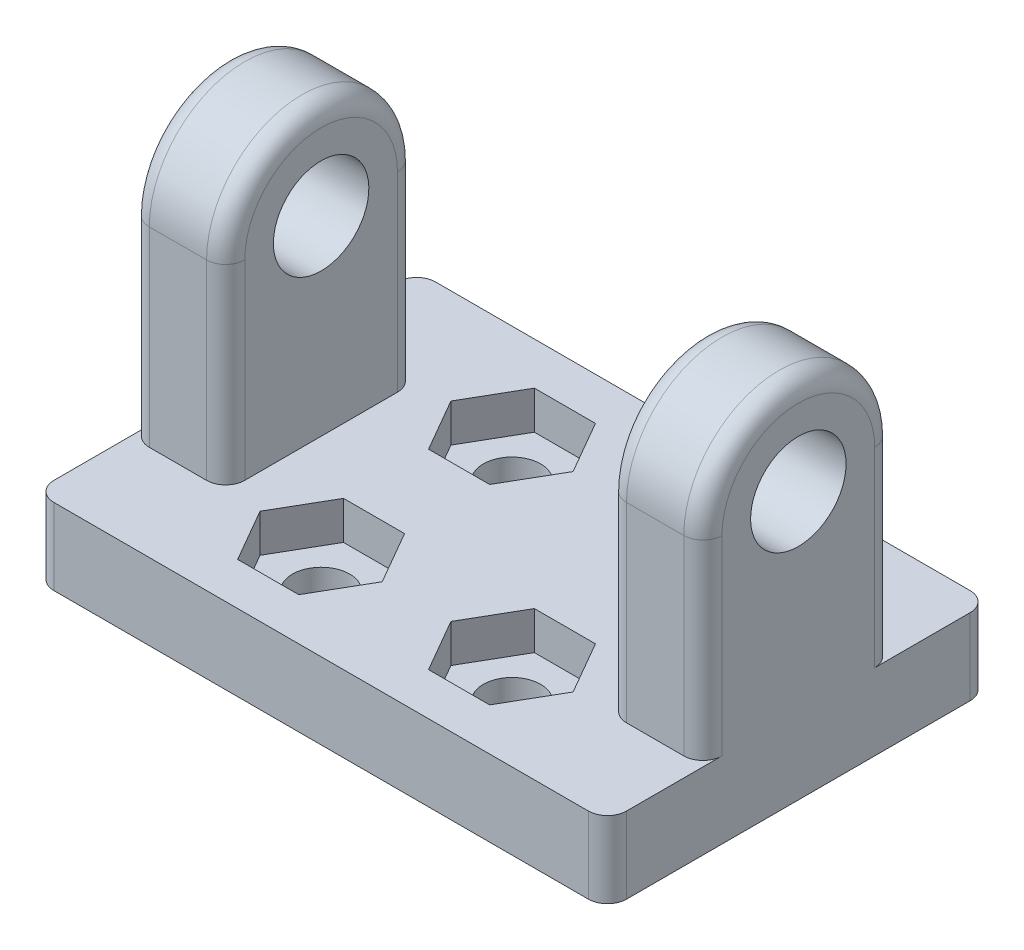
from build123d import *

# Parameters (mm, degrees)
ESQUISSE2_R                  = 2.5
BOSS_EXTRU_1_DEPTH           = 15
ESQUISSE4_W                  = 30
ESQUISSE4_H                  = 20
BOSS_EXTRU_2_DEPTH           = 4
ENL_V_MAT_EXTRU_1_REACH      = 6
ESQUISSE5_R                  = 1.5
ESQUISSE6_W                  = 20
ESQUISSE6_H                  = 21.543710407
ENL_V_MAT_EXTRU_2_DEPTH      = 16
ENL_V_MAT_EXTRU_3_DEPTH      = 16
ENL_V_MAT_EXTRU_3_DEPTH_BACK = 2
CONG_1_R                     = 1


with BuildPart() as part:
    # Esquisse2 → Boss.-Extru.1 (new body, symmetric)
    with BuildSketch(Plane(origin=(0, 0, 0), x_dir=(0, 0, -1), z_dir=(1, 0, 0))):
        with BuildLine():
            Line((5, 0), (5, -10))
            Line((5, -10), (-5, -10))
            Line((-5, -10), (-5, 0))
            ThreePointArc((-5, 0), (0, 5), (5, 0))
        make_face()
        Circle(ESQUISSE2_R, mode=Mode.SUBTRACT)
    extrude(amount=BOSS_EXTRU_1_DEPTH, both=True)

    # Esquisse4 → Boss.-Extru.2 (add)
    with BuildSketch(Plane.XZ.offset(10)):
        Rectangle(ESQUISSE4_W, ESQUISSE4_H)
    extrude(amount=BOSS_EXTRU_2_DEPTH)

    # Esquisse5 → Enlèv. mat.-Extru.1 (cut, up to next)
    with BuildSketch(Plane(origin=(0, -10, 0), x_dir=(1, 0, 0), z_dir=(0, 1, 0)), mode=Mode.PRIVATE) as enl_v_mat_extru_1_sk1:
        with Locations(Location((5, -5, 0), (0, 0, 270))):  # turned: the seam where the file's is
            Circle(ESQUISSE5_R)
    enl_v_mat_extru_1_tool1 = extrude(enl_v_mat_extru_1_sk1.sketch, amount=-ENL_V_MAT_EXTRU_1_REACH, mode=Mode.PRIVATE) & part.part
    add(enl_v_mat_extru_1_tool1.solids().sort_by_distance((5, -10, 5))[0], mode=Mode.SUBTRACT)
    # Esquisse5 → Enlèv. mat.-Extru.1 (cut, up to next)
    with BuildSketch(Plane(origin=(0, -10, 0), x_dir=(1, 0, 0), z_dir=(0, 1, 0)), mode=Mode.PRIVATE) as enl_v_mat_extru_1_sk2:
        with Locations(Location((5, 5, 0), (0, 0, 270))):  # turned: the seam where the file's is
            Circle(ESQUISSE5_R)
    enl_v_mat_extru_1_tool2 = extrude(enl_v_mat_extru_1_sk2.sketch, amount=-ENL_V_MAT_EXTRU_1_REACH, mode=Mode.PRIVATE) & part.part
    add(enl_v_mat_extru_1_tool2.solids().sort_by_distance((5, -10, -5))[0], mode=Mode.SUBTRACT)
    # Esquisse5 → Enlèv. mat.-Extru.1 (cut, up to next)
    with BuildSketch(Plane(origin=(0, -10, 0), x_dir=(1, 0, 0), z_dir=(0, 1, 0)), mode=Mode.PRIVATE) as enl_v_mat_extru_1_sk3:
        with Locations(Location((-5, 5, 0), (0, 0, 270))):  # turned: the seam where the file's is
            Circle(ESQUISSE5_R)
    enl_v_mat_extru_1_tool3 = extrude(enl_v_mat_extru_1_sk3.sketch, amount=-ENL_V_MAT_EXTRU_1_REACH, mode=Mode.PRIVATE) & part.part
    add(enl_v_mat_extru_1_tool3.solids().sort_by_distance((-5, -10, -5))[0], mode=Mode.SUBTRACT)
    # Esquisse5 → Enlèv. mat.-Extru.1 (cut, up to next)
    with BuildSketch(Plane(origin=(0, -10, 0), x_dir=(1, 0, 0), z_dir=(0, 1, 0)), mode=Mode.PRIVATE) as enl_v_mat_extru_1_sk4:
        with Locations(Location((-5, -5, 0), (0, 0, 270))):  # turned: the seam where the file's is
            Circle(ESQUISSE5_R)
    enl_v_mat_extru_1_tool4 = extrude(enl_v_mat_extru_1_sk4.sketch, amount=-ENL_V_MAT_EXTRU_1_REACH, mode=Mode.PRIVATE) & part.part
    add(enl_v_mat_extru_1_tool4.solids().sort_by_distance((-5, -10, 5))[0], mode=Mode.SUBTRACT)

    # Esquisse6 → Enlèv. mat.-Extru.2 (cut, through all)
    with BuildSketch(Plane.XY.offset(5)):
        with Locations((0, 0.771855204)):
            Rectangle(ESQUISSE6_W, ESQUISSE6_H)
    extrude(amount=-ENL_V_MAT_EXTRU_2_DEPTH, mode=Mode.SUBTRACT)

    # Esquisse7 → Enlèv. mat.-Extru.3 (cut, two sides)
    with BuildSketch(Plane(origin=(0, -10, 0), x_dir=(1, 0, 0), z_dir=(0, 1, 0))) as enl_v_mat_extru_3_sk:
        Polygon((-1.8, -5), (-3.4, -2.228718708), (-6.6, -2.228718708), (-8.2, -5), (-6.6, -7.771281292), (-3.4, -7.771281292), align=None)
        Polygon((8.2, -5), (6.6, -2.228718708), (3.4, -2.228718708), (1.8, -5), (3.4, -7.771281292), (6.6, -7.771281292), align=None)
        Polygon((8.2, 5), (6.6, 7.771281292), (3.4, 7.771281292), (1.8, 5), (3.4, 2.228718708), (6.6, 2.228718708), align=None)
        Polygon((-1.8, 5), (-3.4, 7.771281292), (-6.6, 7.771281292), (-8.2, 5), (-6.6, 2.228718708), (-3.4, 2.228718708), align=None)
    extrude(amount=ENL_V_MAT_EXTRU_3_DEPTH, mode=Mode.SUBTRACT)
    extrude(enl_v_mat_extru_3_sk.sketch, amount=-ENL_V_MAT_EXTRU_3_DEPTH_BACK, mode=Mode.SUBTRACT)

    # Congé1
    cong_1_edges = [part.edges().sort_by_distance(p)[0] for p in [
        (15, -5, -5),
        (-15, -12, 10),
        (-15, -12, -10),
        (15, -12, -10),
        (15, -12, 10),
        (15, 5, 0),
        (-15, -5, -5),
        (-15, -5, 5),
        (-15, 5, 0),
        (-10, 5, 0),
        (-10, -5, -5),
        (10, -5, -5),
        (10, 5, 0),
        (10, -5, 5),
        (-10, -5, 5),
        (15, -5, 5),
    ]]
    fillet(cong_1_edges, radius=CONG_1_R)


solid = part.part
